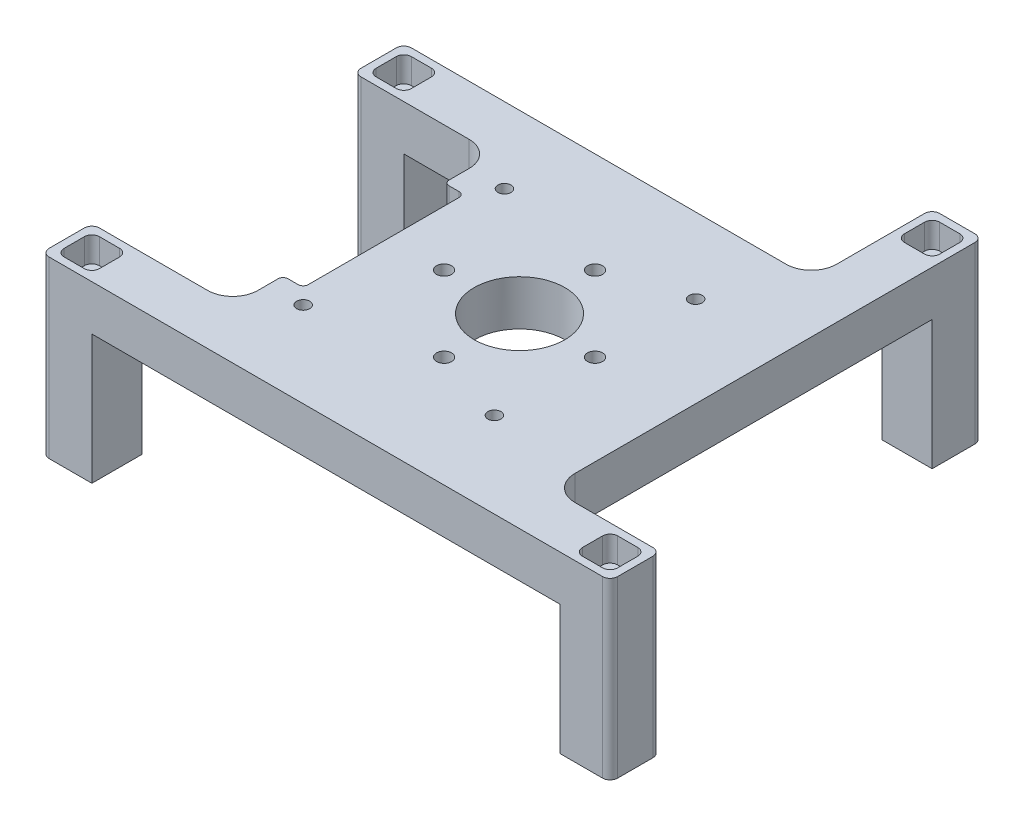
from build123d import *

# Parameters (mm, degrees)
BOSS_EXTRUDE1_DEPTH = 9
CUT_EXTRUDE1_REACH  = 11
SKETCH2_R           = 9
SKETCH2_R_2         = 1.5
CUT_EXTRUDE2_REACH  = 11
SKETCH3_R           = 1.3
SKETCH4_W           = 10
SKETCH4_H           = 10
BOSS_EXTRUDE2_DEPTH = 25.7
SKETCH5_W           = 10
SKETCH5_H           = 10
BOSS_EXTRUDE3_DEPTH = 25.7
SKETCH6_W           = 10
SKETCH6_H           = 10
BOSS_EXTRUDE4_DEPTH = 25.7
SKETCH7_W           = 10
SKETCH7_H           = 10
BOSS_EXTRUDE5_DEPTH = 25.7
SKETCH8_W           = 7
SKETCH8_H           = 7
CUT_EXTRUDE3_DEPTH  = 5
CUT_EXTRUDE4_REACH  = 31.7
SKETCH9_R           = 1.7
FILLET1_R           = 1.5
FILLET2_R           = 5
CUT_EXTRUDE7_DEPTH  = 3
FILLET3_R           = 1


with BuildPart() as part:
    # Sketch1 → Boss-Extrude1 (new body)
    with BuildSketch(Plane(origin=(0, 0, 0), x_dir=(1, 0, 0), z_dir=(0, 1, 0))):
        Polygon((-30, -27), (-30, -17), (-26, -17), (-26, 15), (-30, 15), (-30, 25), (-58, 25), (-58, 35), (23, 35), (23, 59), (33, 59), (33, 35), (33, -27), (55, -27), (55, -37), (33, -37), (-26, -37), (-58, -37), (-58, -27), align=None)
    extrude(amount=BOSS_EXTRUDE1_DEPTH)

    # Sketch2 → Cut-Extrude1 (cut, up to next)
    with BuildSketch(Plane(origin=(0, 9, 0), x_dir=(1, 0, 0), z_dir=(0, 1, 0)), mode=Mode.PRIVATE) as cut_extrude1_sk1:
        Circle(SKETCH2_R)
    cut_extrude1_tool1 = extrude(cut_extrude1_sk1.sketch, amount=-CUT_EXTRUDE1_REACH, mode=Mode.PRIVATE) & part.part
    add(cut_extrude1_tool1.solids().sort_by_distance((0, 9, 0))[0], mode=Mode.SUBTRACT)
    # Sketch2 → Cut-Extrude1 (cut, up to next)
    with BuildSketch(Plane(origin=(0, 9, 0), x_dir=(1, 0, 0), z_dir=(0, 1, 0)), mode=Mode.PRIVATE) as cut_extrude1_sk2:
        with Locations((0, 15)):
            Circle(SKETCH2_R_2)
    cut_extrude1_tool2 = extrude(cut_extrude1_sk2.sketch, amount=-CUT_EXTRUDE1_REACH, mode=Mode.PRIVATE) & part.part
    add(cut_extrude1_tool2.solids().sort_by_distance((0, 9, -15))[0], mode=Mode.SUBTRACT)
    # Sketch2 → Cut-Extrude1 (cut, up to next)
    with BuildSketch(Plane(origin=(0, 9, 0), x_dir=(1, 0, 0), z_dir=(0, 1, 0)), mode=Mode.PRIVATE) as cut_extrude1_sk3:
        with Locations((15, 0)):
            Circle(SKETCH2_R_2)
    cut_extrude1_tool3 = extrude(cut_extrude1_sk3.sketch, amount=-CUT_EXTRUDE1_REACH, mode=Mode.PRIVATE) & part.part
    add(cut_extrude1_tool3.solids().sort_by_distance((15, 9, 0))[0], mode=Mode.SUBTRACT)
    # Sketch2 → Cut-Extrude1 (cut, up to next)
    with BuildSketch(Plane(origin=(0, 9, 0), x_dir=(1, 0, 0), z_dir=(0, 1, 0)), mode=Mode.PRIVATE) as cut_extrude1_sk4:
        with Locations((0, -15)):
            Circle(SKETCH2_R_2)
    cut_extrude1_tool4 = extrude(cut_extrude1_sk4.sketch, amount=-CUT_EXTRUDE1_REACH, mode=Mode.PRIVATE) & part.part
    add(cut_extrude1_tool4.solids().sort_by_distance((0, 9, 15))[0], mode=Mode.SUBTRACT)
    # Sketch2 → Cut-Extrude1 (cut, up to next)
    with BuildSketch(Plane(origin=(0, 9, 0), x_dir=(1, 0, 0), z_dir=(0, 1, 0)), mode=Mode.PRIVATE) as cut_extrude1_sk5:
        with Locations((-15, 0)):
            Circle(SKETCH2_R_2)
    cut_extrude1_tool5 = extrude(cut_extrude1_sk5.sketch, amount=-CUT_EXTRUDE1_REACH, mode=Mode.PRIVATE) & part.part
    add(cut_extrude1_tool5.solids().sort_by_distance((-15, 9, 0))[0], mode=Mode.SUBTRACT)

    # Sketch3 → Cut-Extrude2 (cut, up to next)
    with BuildSketch(Plane(origin=(0, 9, 0), x_dir=(1, 0, 0), z_dir=(0, 1, 0)), mode=Mode.PRIVATE) as cut_extrude2_sk1:
        with Locations((-23, 20)):
            Circle(SKETCH3_R)
    cut_extrude2_tool1 = extrude(cut_extrude2_sk1.sketch, amount=-CUT_EXTRUDE2_REACH, mode=Mode.PRIVATE) & part.part
    add(cut_extrude2_tool1.solids().sort_by_distance((-23, 9, -20))[0], mode=Mode.SUBTRACT)
    # Sketch3 → Cut-Extrude2 (cut, up to next)
    with BuildSketch(Plane(origin=(0, 9, 0), x_dir=(1, 0, 0), z_dir=(0, 1, 0)), mode=Mode.PRIVATE) as cut_extrude2_sk2:
        with Locations((-23, -20)):
            Circle(SKETCH3_R)
    cut_extrude2_tool2 = extrude(cut_extrude2_sk2.sketch, amount=-CUT_EXTRUDE2_REACH, mode=Mode.PRIVATE) & part.part
    add(cut_extrude2_tool2.solids().sort_by_distance((-23, 9, 20))[0], mode=Mode.SUBTRACT)
    # Sketch3 → Cut-Extrude2 (cut, up to next)
    with BuildSketch(Plane(origin=(0, 9, 0), x_dir=(1, 0, 0), z_dir=(0, 1, 0)), mode=Mode.PRIVATE) as cut_extrude2_sk3:
        with Locations((15, 20)):
            Circle(SKETCH3_R)
    cut_extrude2_tool3 = extrude(cut_extrude2_sk3.sketch, amount=-CUT_EXTRUDE2_REACH, mode=Mode.PRIVATE) & part.part
    add(cut_extrude2_tool3.solids().sort_by_distance((15, 9, -20))[0], mode=Mode.SUBTRACT)
    # Sketch3 → Cut-Extrude2 (cut, up to next)
    with BuildSketch(Plane(origin=(0, 9, 0), x_dir=(1, 0, 0), z_dir=(0, 1, 0)), mode=Mode.PRIVATE) as cut_extrude2_sk4:
        with Locations((15, -20)):
            Circle(SKETCH3_R)
    cut_extrude2_tool4 = extrude(cut_extrude2_sk4.sketch, amount=-CUT_EXTRUDE2_REACH, mode=Mode.PRIVATE) & part.part
    add(cut_extrude2_tool4.solids().sort_by_distance((15, 9, 20))[0], mode=Mode.SUBTRACT)

    # Sketch4 → Boss-Extrude2 (add)
    with BuildSketch(Plane.XZ):
        with Locations((-53, -30)):
            Rectangle(SKETCH4_W, SKETCH4_H)
    extrude(amount=BOSS_EXTRUDE2_DEPTH)

    # Sketch5 → Boss-Extrude3 (add)
    with BuildSketch(Plane.XZ):
        with Locations((-53, 32)):
            Rectangle(SKETCH5_W, SKETCH5_H)
    extrude(amount=BOSS_EXTRUDE3_DEPTH)

    # Sketch6 → Boss-Extrude4 (add)
    with BuildSketch(Plane.XZ):
        with Locations((28, -54)):
            Rectangle(SKETCH6_W, SKETCH6_H)
    extrude(amount=BOSS_EXTRUDE4_DEPTH)

    # Sketch7 → Boss-Extrude5 (add)
    with BuildSketch(Plane.XZ):
        with Locations((50, 32)):
            Rectangle(SKETCH7_W, SKETCH7_H)
    extrude(amount=BOSS_EXTRUDE5_DEPTH)

    # Sketch8 → Cut-Extrude3 (cut)
    with BuildSketch(Plane(origin=(0, 9, 0), x_dir=(1, 0, 0), z_dir=(0, 1, 0))):
        with Locations((-53, 30)):
            Rectangle(SKETCH8_W, SKETCH8_H)
        with Locations((-53, -32)):
            Rectangle(SKETCH8_W, SKETCH8_H)
        with Locations((50, -32)):
            Rectangle(SKETCH8_W, SKETCH8_H)
        with Locations((28, 54)):
            Rectangle(SKETCH8_W, SKETCH8_H)
    extrude(amount=-CUT_EXTRUDE3_DEPTH, mode=Mode.SUBTRACT)

    # Sketch9 → Cut-Extrude4 (cut, up to next)
    with BuildSketch(Plane(origin=(0, 4, 0), x_dir=(1, 0, 0), z_dir=(0, 1, 0)), mode=Mode.PRIVATE) as cut_extrude4_sk1:
        with Locations((-53, 30)):
            Circle(SKETCH9_R)
    cut_extrude4_tool1 = extrude(cut_extrude4_sk1.sketch, amount=-CUT_EXTRUDE4_REACH, mode=Mode.PRIVATE) & part.part
    add(cut_extrude4_tool1.solids().sort_by_distance((-53, 4, -30))[0], mode=Mode.SUBTRACT)
    # Sketch9 → Cut-Extrude4 (cut, up to next)
    with BuildSketch(Plane(origin=(0, 4, 0), x_dir=(1, 0, 0), z_dir=(0, 1, 0)), mode=Mode.PRIVATE) as cut_extrude4_sk2:
        with Locations((28, 54)):
            Circle(SKETCH9_R)
    cut_extrude4_tool2 = extrude(cut_extrude4_sk2.sketch, amount=-CUT_EXTRUDE4_REACH, mode=Mode.PRIVATE) & part.part
    add(cut_extrude4_tool2.solids().sort_by_distance((28, 4, -54))[0], mode=Mode.SUBTRACT)
    # Sketch9 → Cut-Extrude4 (cut, up to next)
    with BuildSketch(Plane(origin=(0, 4, 0), x_dir=(1, 0, 0), z_dir=(0, 1, 0)), mode=Mode.PRIVATE) as cut_extrude4_sk3:
        with Locations((50, -32)):
            Circle(SKETCH9_R)
    cut_extrude4_tool3 = extrude(cut_extrude4_sk3.sketch, amount=-CUT_EXTRUDE4_REACH, mode=Mode.PRIVATE) & part.part
    add(cut_extrude4_tool3.solids().sort_by_distance((50, 4, 32))[0], mode=Mode.SUBTRACT)
    # Sketch9 → Cut-Extrude4 (cut, up to next)
    with BuildSketch(Plane(origin=(0, 4, 0), x_dir=(1, 0, 0), z_dir=(0, 1, 0)), mode=Mode.PRIVATE) as cut_extrude4_sk4:
        with Locations((-53, -32)):
            Circle(SKETCH9_R)
    cut_extrude4_tool4 = extrude(cut_extrude4_sk4.sketch, amount=-CUT_EXTRUDE4_REACH, mode=Mode.PRIVATE) & part.part
    add(cut_extrude4_tool4.solids().sort_by_distance((-53, 4, 32))[0], mode=Mode.SUBTRACT)

    # Fillet1
    fillet1_edges = [part.edges().sort_by_distance(p)[0] for p in [
        (24.5, 6.5, -57.5),
        (24.5, 6.5, -50.5),
        (31.5, 6.5, -50.5),
        (31.5, 6.5, -57.5),
        (46.5, 6.5, 28.5),
        (46.5, 6.5, 35.5),
        (53.5, 6.5, 35.5),
        (53.5, 6.5, 28.5),
        (-56.5, 6.5, 28.5),
        (-56.5, 6.5, 35.5),
        (-49.5, 6.5, 35.5),
        (-49.5, 6.5, 28.5),
        (-49.5, 6.5, -26.5),
        (-49.5, 6.5, -33.5),
        (-56.5, 6.5, -33.5),
        (-56.5, 6.5, -26.5),
        (-58, -8.35, -35),
        (23, -8.35, -59),
        (33, -8.35, -59),
        (55, -8.35, 27),
        (55, -8.35, 37),
        (-58, -8.35, 37),
        (-58, -8.35, 27),
        (-58, -8.35, -25),
    ]]
    fillet(fillet1_edges, radius=FILLET1_R)

    # Fillet2
    fillet2_edges = [part.edges().sort_by_distance(p)[0] for p in [
        (23, 4.5, -35),
        (33, 4.5, 27),
        (-30, 4.5, 27),
        (-30, 4.5, -25),
    ]]
    fillet(fillet2_edges, radius=FILLET2_R)

    # Sketch12 → Cut-Extrude7 (cut)
    with BuildSketch(Plane.XZ):
        Polygon((-19.9, 18.210214166), (-19.9, 21.789785834), (-23, 23.579571669), (-26.1, 21.789785834), (-26.1, 18.210214166), (-23, 16.420428331), align=None)
        Polygon((18.1, 21.789785834), (15, 23.579571669), (11.9, 21.789785834), (11.9, 18.210214166), (15, 16.420428331), (18.1, 18.210214166), align=None)
        Polygon((18.1, -18.210214166), (15, -16.420428331), (11.9, -18.210214166), (11.9, -21.789785834), (15, -23.579571669), (18.1, -21.789785834), align=None)
        Polygon((-19.9, -18.210214166), (-23, -16.420428331), (-26.1, -18.210214166), (-26.1, -21.789785834), (-23, -23.579571669), (-19.9, -21.789785834), align=None)
    extrude(amount=-CUT_EXTRUDE7_DEPTH, mode=Mode.SUBTRACT)

    # Fillet3
    fillet3_edges = [part.edges().sort_by_distance(p)[0] for p in [
        (-30, 4.5, 17),
        (-26, 4.5, 17),
        (-26, 4.5, -15),
        (-30, 4.5, -15),
    ]]
    fillet(fillet3_edges, radius=FILLET3_R)


solid = part.part
